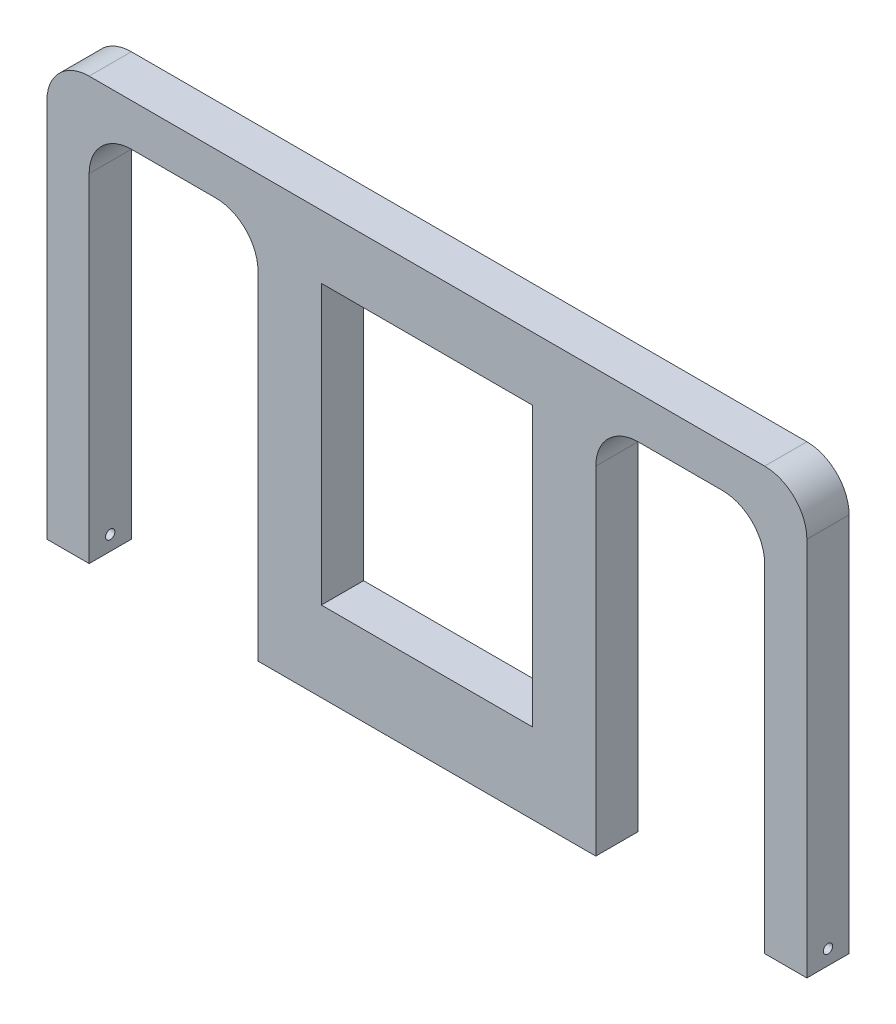
from build123d import *

# Parameters (mm, degrees)
SKETCH1_W             = 12.7
SKETCH1_H             = 12.7
BOSS_EXTRUDE1_DEPTH   = 114.3
BOSS_EXTRUDE1_2_DEPTH = 114.3
SKETCH2_W             = 12.7
SKETCH2_H             = 12.7
BOSS_EXTRUDE2_DEPTH   = 228.6
SKETCH3_W             = 101.6
SKETCH3_H             = 12.7
BOSS_EXTRUDE3_DEPTH   = 114.3
SKETCH4_R             = 1.397
CUT_EXTRUDE1_DEPTH    = 12.7
BOSS_EXTRUDE4_DEPTH   = 12.7
CUT_EXTRUDE2_DEPTH    = 12.7
SKETCH7_W             = 63.5
SKETCH7_H             = 83.82
CUT_EXTRUDE3_DEPTH    = 12.7


with BuildPart() as part:
    # Sketch1 → Boss-Extrude1 (new body)
    with BuildSketch(Plane(origin=(0, 0, 0), x_dir=(1, 0, 0), z_dir=(0, 1, 0))):
        with Locations((-107.95, -6.35)):
            Rectangle(SKETCH1_W, SKETCH1_H)
    extrude(amount=BOSS_EXTRUDE1_DEPTH)



with BuildPart() as body_2:
    # Sketch1 → Boss-Extrude1 2 (new body)
    with BuildSketch(Plane(origin=(0, 0, 0), x_dir=(1, 0, 0), z_dir=(0, 1, 0))):
        with Locations((107.95, -6.35)):
            Rectangle(SKETCH1_W, SKETCH1_H)
    extrude(amount=BOSS_EXTRUDE1_2_DEPTH)


with BuildPart() as part_1:
    add(part.part)

    add(body_2.part)  # Boss-Extrude2 merges body 2
    # Sketch2 → Boss-Extrude2 (add)
    with BuildSketch(Plane.ZY.offset(114.3)):
        with Locations((6.35, 120.65)):
            Rectangle(SKETCH2_W, SKETCH2_H)
    extrude(amount=-BOSS_EXTRUDE2_DEPTH)

    # Sketch3 → Boss-Extrude3 (add)
    with BuildSketch(Plane.XZ.offset(-114.3)):
        with Locations((0, 6.35)):
            Rectangle(SKETCH3_W, SKETCH3_H)
    extrude(amount=BOSS_EXTRUDE3_DEPTH)

    # Sketch4 → Cut-Extrude1 (cut)
    with BuildSketch(Plane(origin=(114.3, 0, 0), x_dir=(0, 0, -1), z_dir=(1, 0, 0))):
        with Locations((-6.35, 4.445)):
            Circle(SKETCH4_R)
    cut_extrude1 = extrude(amount=-CUT_EXTRUDE1_DEPTH, mode=Mode.SUBTRACT)

    # Mirror1: Cut-Extrude1 across plane
    add(cut_extrude1.mirror(Plane(origin=(0, 0, 0), x_dir=(0, 0, 1), z_dir=(1, 0, 0))), mode=Mode.SUBTRACT)

    # Sketch5 → Boss-Extrude4 (add)
    with BuildSketch(Plane(origin=(0, 0, 0), x_dir=(-1, 0, 0), z_dir=(0, 0, -1))):
        with BuildLine():
            Line((-101.6, 114.3), (-101.6, 101.6))
            ThreePointArc((-101.6, 101.6), (-97.880256121, 110.580256121), (-88.9, 114.3))
            Line((-88.9, 114.3), (-101.6, 114.3))
        make_face()
        with BuildLine():
            Line((-50.8, 114.3), (-63.5, 114.3))
            ThreePointArc((-63.5, 114.3), (-54.519743879, 110.580256121), (-50.8, 101.6))
            Line((-50.8, 101.6), (-50.8, 114.3))
        make_face()
    boss_extrude4 = extrude(amount=-BOSS_EXTRUDE4_DEPTH)

    # Mirror2: Boss-Extrude4 across plane
    add(boss_extrude4.mirror(Plane(origin=(0, 0, 0), x_dir=(0, 0, 1), z_dir=(1, 0, 0))))

    # Sketch6 → Cut-Extrude2 (cut)
    with BuildSketch(Plane(origin=(0, 0, 0), x_dir=(-1, 0, 0), z_dir=(0, 0, -1))):
        with BuildLine():
            Line((-114.3, 127), (-114.3, 114.3))
            ThreePointArc((-114.3, 114.3), (-110.580256121, 123.280256121), (-101.6, 127))
            Line((-101.6, 127), (-114.3, 127))
        make_face()
    cut_extrude2 = extrude(amount=-CUT_EXTRUDE2_DEPTH, mode=Mode.SUBTRACT)

    # Mirror3: Cut-Extrude2 across plane
    add(cut_extrude2.mirror(Plane(origin=(0, 0, 0), x_dir=(0, 0, 1), z_dir=(1, 0, 0))), mode=Mode.SUBTRACT)

    # Sketch7 → Cut-Extrude3 (cut)
    with BuildSketch(Plane(origin=(0, 0, 0), x_dir=(-1, 0, 0), z_dir=(0, 0, -1))):
        with Locations((0, 66.04)):
            Rectangle(SKETCH7_W, SKETCH7_H)
    extrude(amount=-CUT_EXTRUDE3_DEPTH, mode=Mode.SUBTRACT)


solid = part_1.part
